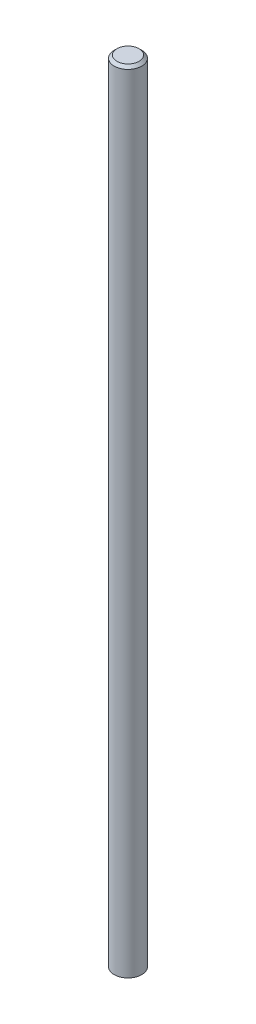
from build123d import *

# Parameters (mm, degrees)
SKETCH1_R           = 1.5
BOSS_EXTRUDE1_DEPTH = 86
CHAMFER1_SIZE       = 0.3


with BuildPart() as part:
    # Sketch1 → Boss-Extrude1 (new body)
    with BuildSketch(Plane(origin=(0, 0, 0), x_dir=(1, 0, 0), z_dir=(0, 1, 0))):
        Circle(SKETCH1_R)
    extrude(amount=BOSS_EXTRUDE1_DEPTH)

    # Chamfer1
    chamfer1_edges = [part.edges().sort_by_distance(p)[0] for p in [
        (-1.5, 86, 0),
    ]]
    chamfer(chamfer1_edges, length=CHAMFER1_SIZE)


solid = part.part
